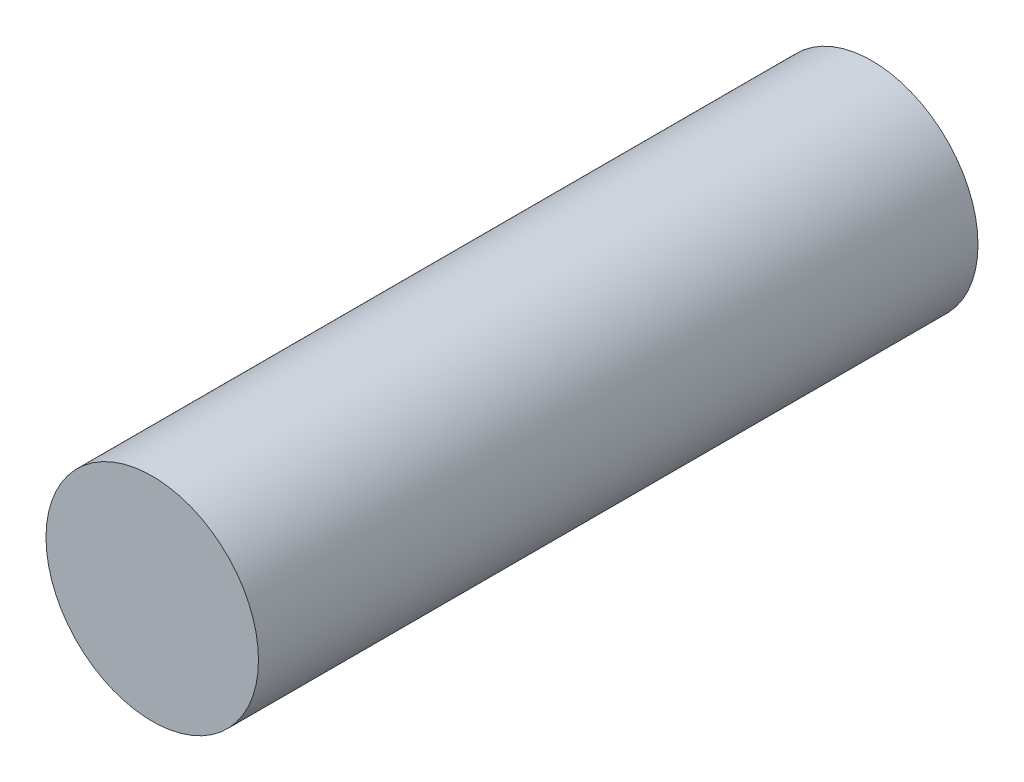
from build123d import *

# Parameters (mm, degrees)
SKETCH_1_R      = 22.147087182
EXTRUDE_1_DEPTH = 150


with BuildPart() as part:
    # 草图1 → 凸台-拉伸1 (new body)
    with BuildSketch(Plane.XY):
        Circle(SKETCH_1_R)
    extrude(amount=EXTRUDE_1_DEPTH)


solid = part.part
